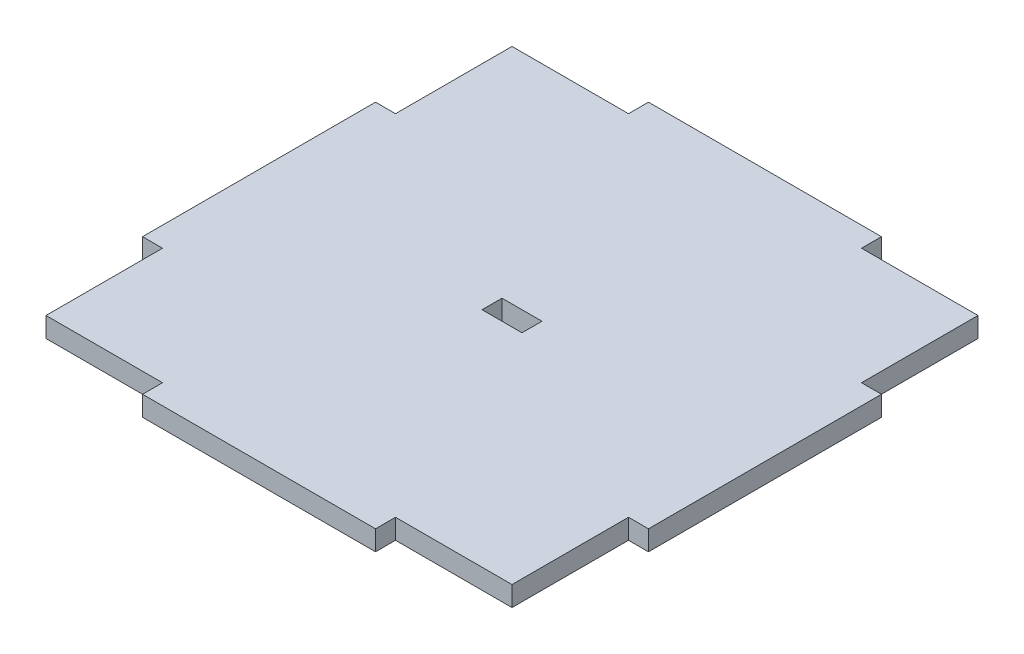
from build123d import *

# Parameters (mm, degrees)
BOSS_EXTRUDE1_DEPTH = 3
SKETCH2_W           = 6
SKETCH2_H           = 3
CUT_EXTRUDE1_DEPTH  = 3


with BuildPart() as part:
    # Sketch1 → Boss-Extrude1 (new body)
    with BuildSketch(Plane(origin=(0, 0, 0), x_dir=(1, 0, 0), z_dir=(0, 1, 0))):
        Polygon((-35, -35), (-17.5, -35), (-17.5, -38), (17.5, -38), (17.5, -35), (35, -35), (35, -17.5), (38, -17.5), (38, 17.5), (35, 17.5), (35, 35), (17.5, 35), (17.5, 38), (-17.5, 38), (-17.5, 35), (-35, 35), (-35, 17.5), (-38, 17.5), (-38, -17.5), (-35, -17.5), align=None)
    extrude(amount=BOSS_EXTRUDE1_DEPTH)

    # Sketch2 → Cut-Extrude1 (cut)
    with BuildSketch(Plane(origin=(0, 3, 0), x_dir=(1, 0, 0), z_dir=(0, 1, 0))):
        Rectangle(SKETCH2_W, SKETCH2_H)
    extrude(amount=-CUT_EXTRUDE1_DEPTH, mode=Mode.SUBTRACT)


solid = part.part
